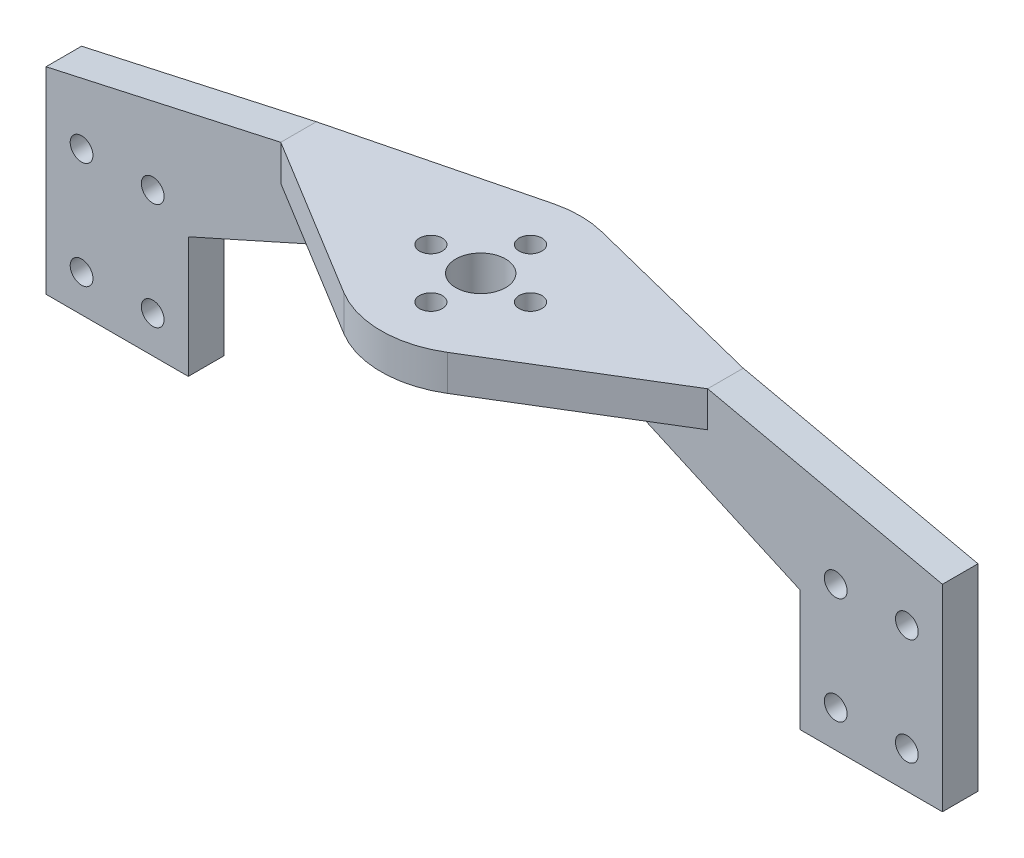
from build123d import *

# Parameters (mm, degrees)
SKETCH_1_R          = 1.6
SKETCH_1_R_2        = 3.5
EXTRUDE_1_DEPTH     = 5
SKETCH_3_R          = 1.6
EXTRUDE_3_DEPTH     = 5
EXTRUDE_4_DEPTH     = 5
CUT_EXTRUDE_1_DEPTH = 21.9


with BuildPart() as part:
    # 草图1 → 凸台-拉伸1 (new body)
    with BuildSketch(Plane(origin=(0, 0, 0), x_dir=(1, 0, 0), z_dir=(0, 1, 0))):
        with BuildLine():
            Line((30, 23.923257503), (36.791550388, 23.923257503))
            Line((36.791550388, 23.923257503), (45, 23.923257503))
            Line((45, 23.923257503), (45, 18.923257503))
            Line((45, 18.923257503), (30, 18.923257503))
            Line((30, 18.923257503), (7.290296698, 5.071204372))
            ThreePointArc((7.290296698, 5.071204372), (0, 3.023257503), (-7.290296698, 5.071204372))
            Line((-7.290296698, 5.071204372), (-30, 18.923257503))
            Line((-30, 18.923257503), (-45, 18.923257503))
            Line((-45, 18.923257503), (-45, 23.923257503))
            Line((-45, 23.923257503), (-36.791550388, 23.923257503))
            Line((-36.791550388, 23.923257503), (-30, 23.923257503))
            Line((-30, 23.923257503), (-3.410329214, 30.601536284))
            ThreePointArc((-3.410329214, 30.601536284), (0, 31.023257503), (3.410329214, 30.601536284))
            Line((3.410329214, 30.601536284), (30, 23.923257503))
        make_face()
        with Locations((0, 24.023257503)):
            Circle(SKETCH_1_R, mode=Mode.SUBTRACT)
        with Locations((0, 10.023257503)):
            Circle(SKETCH_1_R, mode=Mode.SUBTRACT)
        with Locations((-7, 17.023257503)):
            Circle(SKETCH_1_R, mode=Mode.SUBTRACT)
        with Locations((7, 17.023257503)):
            Circle(SKETCH_1_R, mode=Mode.SUBTRACT)
        with Locations((0, 17.023257503)):
            Circle(SKETCH_1_R_2, mode=Mode.SUBTRACT)
    extrude(amount=EXTRUDE_1_DEPTH)

    # 草图3 → 凸台-拉伸3 (add)
    with BuildSketch(Plane(origin=(0, 0, -23.923257503), x_dir=(-1, 0, 0), z_dir=(0, 0, -1))):
        Polygon((-45, 5), (-63, 5), (-63, -30), (-43, -30), (-43, -20.44669455), (-43, -7.63227787), (-43, 5), align=None)
        with Locations((-58, -9.8)):
            Circle(SKETCH_3_R, mode=Mode.SUBTRACT)
        with Locations((-58, -24.8)):
            Circle(SKETCH_3_R, mode=Mode.SUBTRACT)
        with Locations((-48, -24.8)):
            Circle(SKETCH_3_R, mode=Mode.SUBTRACT)
        with Locations((-48, -9.8)):
            Circle(SKETCH_3_R, mode=Mode.SUBTRACT)
        Polygon((43, -20.44669455), (43, -30), (63, -30), (63, 5), (45, 5), (43, 5), (43, -7.63227787), align=None)
        with Locations((48, -9.8)):
            Circle(SKETCH_3_R, mode=Mode.SUBTRACT)
        with Locations((48, -24.8)):
            Circle(SKETCH_3_R, mode=Mode.SUBTRACT)
        with Locations((58, -24.8)):
            Circle(SKETCH_3_R, mode=Mode.SUBTRACT)
        with Locations((58, -9.8)):
            Circle(SKETCH_3_R, mode=Mode.SUBTRACT)
    extrude(amount=-EXTRUDE_3_DEPTH)

    # 草图5 → 凸台-拉伸4 (add)
    with BuildSketch(Plane(origin=(0, 0, -23.923257503), x_dir=(-1, 0, 0), z_dir=(0, 0, -1))):
        Polygon((14, 0), (43, -13), (43, 0), align=None)
        Polygon((-43, 0), (-14, 0), (-43, -13), align=None)
    extrude(amount=-EXTRUDE_4_DEPTH)

    # 草图6 → 切除-拉伸1 (cut, through all)
    with BuildSketch(Plane(origin=(0, 0, -23.923257503), x_dir=(-1, 0, 0), z_dir=(0, 0, -1))):
        Polygon((-63, -2.3), (-30, 5), (-63, 5), align=None)
        Polygon((63, -2.3), (30, 5), (63, 5), align=None)
    extrude(amount=-CUT_EXTRUDE_1_DEPTH, mode=Mode.SUBTRACT)


solid = part.part
